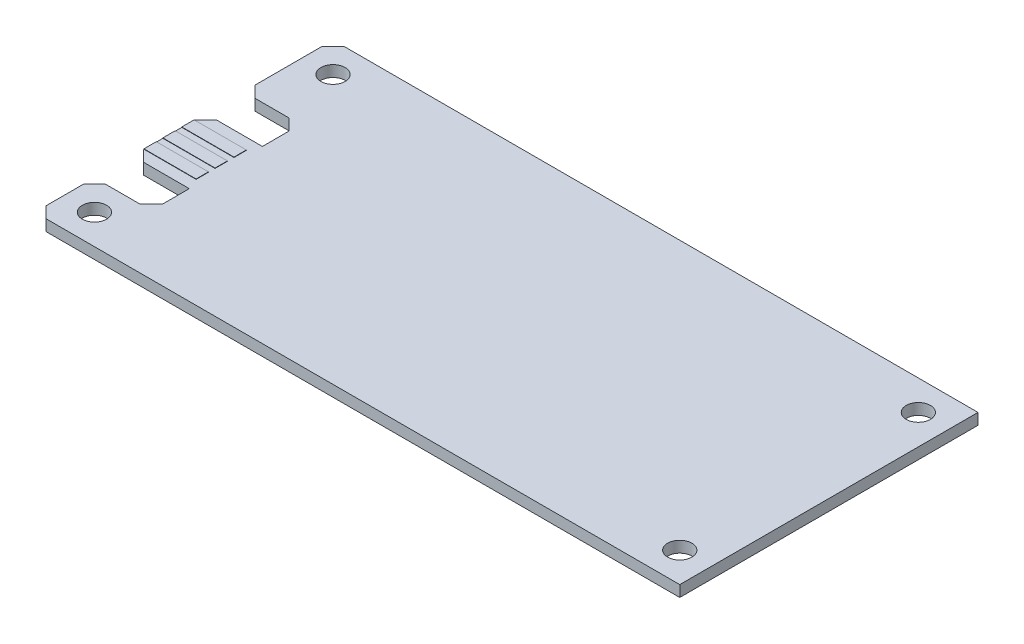
from build123d import *

# Parameters (mm, degrees)
SKETCH1_W                = 86.5
SKETCH1_H                = 40
BOSS_EXTRUDE1_DEPTH      = 1.5
SKETCH2_W                = 7.62
SKETCH2_H                = 5.0978
CUT_EXTRUDE1_DEPTH       = 2.5
CHAMFER2_SIZE            = 1.5
SKETCH4_R                = 1.625
CUT_EXTRUDE2_DEPTH       = 2.5
SKETCH3_W                = 7
SKETCH3_H                = 1.651
BOSS_EXTRUDE2_DEPTH      = 0.05
BOSS_EXTRUDE2_DEPTH_BACK = 1.55


with BuildPart() as part:
    # Sketch1 → Boss-Extrude1 (new body)
    with BuildSketch(Plane(origin=(0, 0, 0), x_dir=(1, 0, 0), z_dir=(0, 1, 0))):
        with Locations((1.75, 0)):
            Rectangle(SKETCH1_W, SKETCH1_H)
    extrude(amount=BOSS_EXTRUDE1_DEPTH)

    # Sketch2 → Cut-Extrude1 (cut, through all)
    with BuildSketch(Plane(origin=(0, 1.5, 0), x_dir=(1, 0, 0), z_dir=(0, 1, 0))):
        with Locations((-37.69, 5.4511)):
            Rectangle(SKETCH2_W, SKETCH2_H)
        with Locations((-37.69, -9.4511)):
            Rectangle(SKETCH2_W, SKETCH2_H)
    extrude(amount=-CUT_EXTRUDE1_DEPTH, mode=Mode.SUBTRACT)

    # Chamfer2
    chamfer2_edges = [part.edges().sort_by_distance(p)[0] for p in [
        (-41.5, 0.75, -2.9022),
        (-41.5, 0.75, -8),
        (-33.88, 0.75, -8),
        (-41.5, 0.75, 12),
        (-41.5, 0.75, 6.9022),
        (-33.88, 0.75, 12),
        (-41.5, 0.75, -20),
        (-41.5, 0.75, 20),
    ]]
    chamfer(chamfer2_edges, length=CHAMFER2_SIZE)

    # Sketch4 → Cut-Extrude2 (cut, through all)
    with BuildSketch(Plane.XZ):
        with Locations((-37.5, 16)):
            Circle(SKETCH4_R)
        with Locations((41, 16)):
            Circle(SKETCH4_R)
        with Locations((41, -16)):
            Circle(SKETCH4_R)
        with Locations((-37.5, -16)):
            Circle(SKETCH4_R)
    extrude(amount=-CUT_EXTRUDE2_DEPTH, mode=Mode.SUBTRACT)

    # Sketch3 → Boss-Extrude2 (add, two sides)
    with BuildSketch(Plane(origin=(0, 1.5, 0), x_dir=(1, 0, 0), z_dir=(0, 1, 0))) as boss_extrude2_sk:
        with Locations((-38, 0.54)):
            Rectangle(SKETCH3_W, SKETCH3_H)
        with Locations((-38, -2)):
            Rectangle(SKETCH3_W, SKETCH3_H)
        with Locations((-38, -4.54)):
            Rectangle(SKETCH3_W, SKETCH3_H)
    extrude(amount=BOSS_EXTRUDE2_DEPTH)
    extrude(boss_extrude2_sk.sketch, amount=-BOSS_EXTRUDE2_DEPTH_BACK)


solid = part.part
